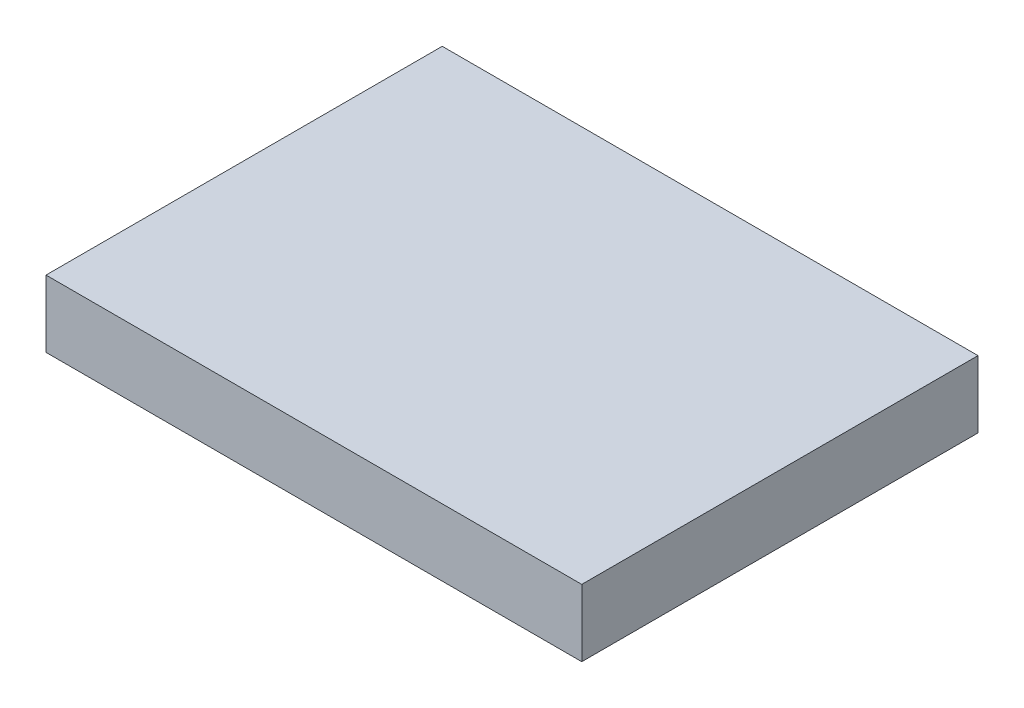
from build123d import *

# Parameters (mm, degrees)
ESQUISSE1_W        = 24
ESQUISSE1_H        = 17.75
BOSS_EXTRU_1_DEPTH = 3


with BuildPart() as part:
    # Esquisse1 → Boss.-Extru.1 (new body)
    with BuildSketch(Plane(origin=(0, 0, 0), x_dir=(1, 0, 0), z_dir=(0, 1, 0))):
        with Locations((-12, 8.875)):
            Rectangle(ESQUISSE1_W, ESQUISSE1_H)
    extrude(amount=BOSS_EXTRU_1_DEPTH)


solid = part.part
